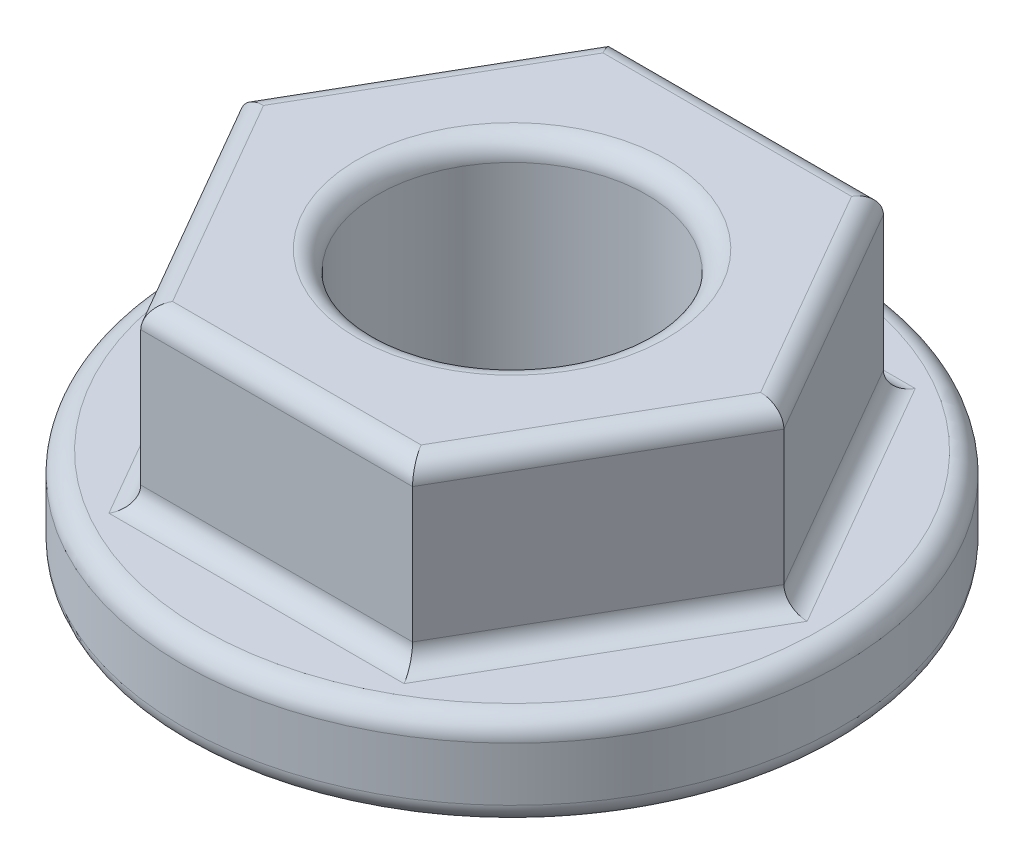
from build123d import *

# Parameters (mm, degrees)
SKETCH1_R           = 4.9
BOSS_EXTRUDE1_DEPTH = 4
SKETCH2_R           = 2
CUT_EXTRUDE1_DEPTH  = 4.8
SKETCH3_OUTSIDE_W   = 14.684
SKETCH3_OUTSIDE_H   = 14.684
CUT_EXTRUDE2_DEPTH  = 2.6
FILLET1_R           = 0.3


with BuildPart() as part:
    # Sketch1 → Boss-Extrude1 (new body)
    with BuildSketch(Plane(origin=(0, 0, 0), x_dir=(1, 0, 0), z_dir=(0, 1, 0))):
        Circle(SKETCH1_R)
    extrude(amount=BOSS_EXTRUDE1_DEPTH)

    # Sketch2 → Cut-Extrude1 (cut)
    with BuildSketch(Plane(origin=(0, 4, 0), x_dir=(1, 0, 0), z_dir=(0, 1, 0))):
        Circle(SKETCH2_R)
    extrude(amount=-CUT_EXTRUDE1_DEPTH, mode=Mode.SUBTRACT)

    # Sketch3 outside → Cut-Extrude2 (cut)
    with BuildSketch(Plane(origin=(0, 4, 0), x_dir=(1, 0, 0), z_dir=(0, 1, 0))):
        Rectangle(SKETCH3_OUTSIDE_W, SKETCH3_OUTSIDE_H)
        Polygon((4.041451884, 0), (2.020725942, 3.5), (-2.020725942, 3.5), (-4.041451884, 0), (-2.020725942, -3.5), (2.020725942, -3.5), align=None, mode=Mode.SUBTRACT)
    extrude(amount=-CUT_EXTRUDE2_DEPTH, mode=Mode.SUBTRACT)

    # Fillet1
    fillet1_edges = [part.edges().sort_by_distance(p)[0] for p in [
        (0, 1.4, 3.5),
        (3.031088913, 1.4, 1.75),
        (3.031088913, 1.4, -1.75),
        (0, 1.4, -3.5),
        (-3.031088913, 1.4, -1.75),
        (-3.031088913, 1.4, 1.75),
        (-4.9, 1.4, 0),
        (-4.9, 0, 0),
        (3.031088913, 4, 1.75),
        (0, 4, 3.5),
        (-3.031088913, 4, 1.75),
        (-3.031088913, 4, -1.75),
        (0, 4, -3.5),
        (3.031088913, 4, -1.75),
        (-2, 0, 0),
        (-2, 4, 0),
    ]]
    fillet(fillet1_edges, radius=FILLET1_R)


solid = part.part
